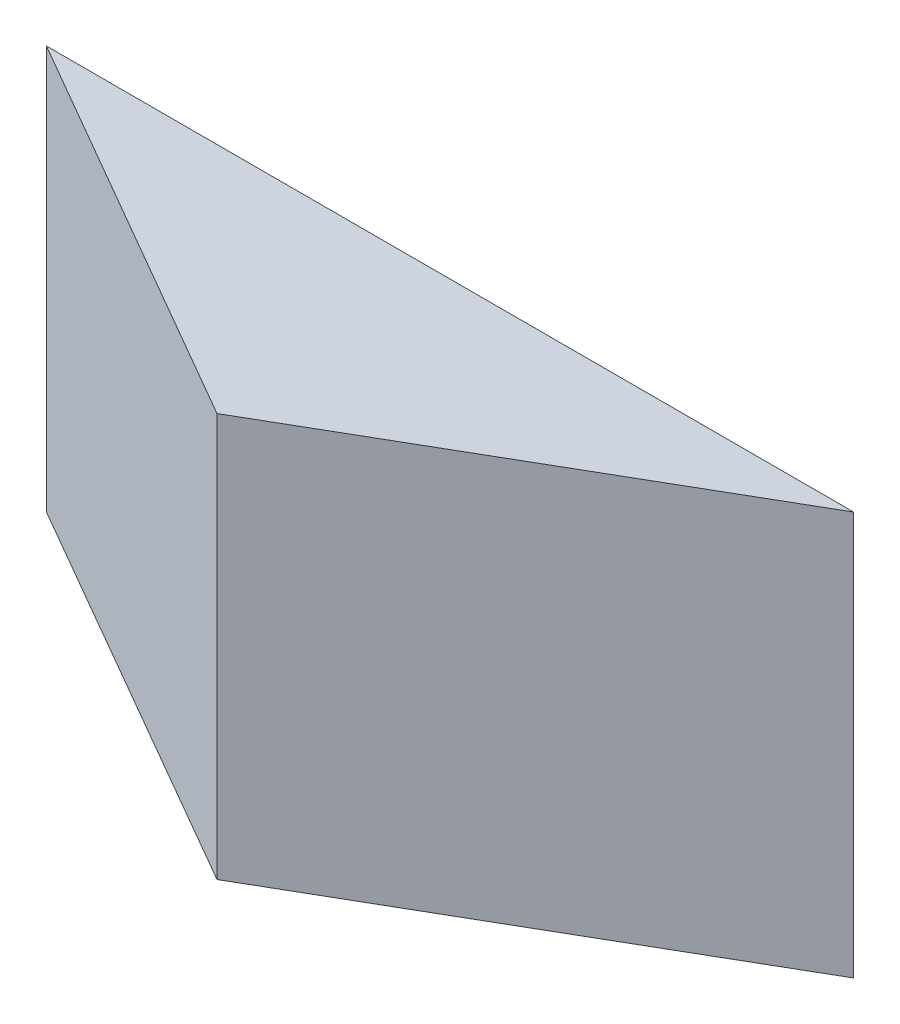
from build123d import *

# Parameters (mm, degrees)
BOSS_EXTRUDE1_DEPTH = 12.7


with BuildPart() as part:
    # Sketch1 → Boss-Extrude1 (new body)
    with BuildSketch(Plane(origin=(0, 0, 0), x_dir=(1, 0, 0), z_dir=(0, 1, 0))):
        Polygon((0, 0), (12.7, 7.332348419), (-12.7, 7.332348419), align=None)
    extrude(amount=BOSS_EXTRUDE1_DEPTH)


solid = part.part
